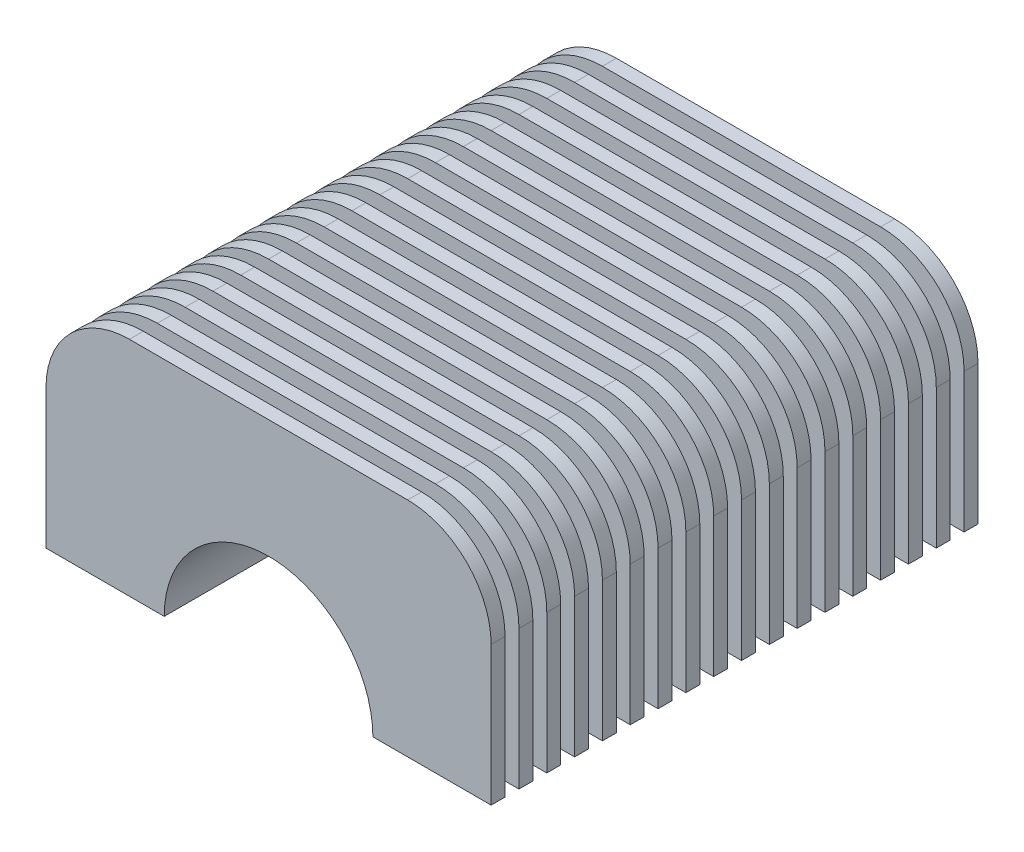
from build123d import *

# Parameters (mm, degrees)
BOSS_EXTRUDE1_DEPTH = 108
FILLET1_R           = 10
FILLET2_R           = 10
BOSS_EXTRUDE3_DEPTH = 3
LPATTERN1_COUNT     = 18
LPATTERN1_PITCH     = 6


with BuildPart() as part:
    # Sketch1 → Boss-Extrude1 (new body)
    with BuildSketch(Plane.XY):
        with BuildLine():
            Line((22.5, 0), (40, 0))
            Line((40, 0), (40, 40))
            Line((40, 40), (-40, 40))
            Line((-40, 40), (-40, 0))
            Line((-40, 0), (-22.5, 0))
            ThreePointArc((-22.5, 0), (0, 22.5), (22.5, 0))
        make_face()
    extrude(amount=BOSS_EXTRUDE1_DEPTH)

    # Fillet1
    fillet1_edges = [part.edges().sort_by_distance(p)[0] for p in [
        (-40, 40, 54),
    ]]
    fillet(fillet1_edges, radius=FILLET1_R)

    # Fillet2
    fillet2_edges = [part.edges().sort_by_distance(p)[0] for p in [
        (40, 40, 54),
    ]]
    fillet(fillet2_edges, radius=FILLET2_R)

    # Sketch3 → Boss-Extrude3 (add)
    with BuildSketch(Plane.XY.offset(108)):
        with BuildLine():
            Line((40, 0), (40, 30))
            ThreePointArc((40, 30), (37.071067812, 37.071067812), (30, 40))
            Line((30, 40), (-30, 40))
            ThreePointArc((-30, 40), (-37.071067812, 37.071067812), (-40, 30))
            Line((-40, 30), (-40, 0))
            Line((-40, 0), (-48, 0))
            Line((-48, 0), (-48, 30))
            ThreePointArc((-48, 30), (-42.727922061, 42.727922061), (-30, 48))
            Line((-30, 48), (30, 48))
            ThreePointArc((30, 48), (42.727922061, 42.727922061), (48, 30))
            Line((48, 30), (48, 0))
            Line((48, 0), (40, 0))
        make_face()
    boss_extrude3 = extrude(amount=-BOSS_EXTRUDE3_DEPTH)

    # LPattern1: Boss-Extrude3 ×18
    with Locations(*[(0, 0, -i * LPATTERN1_PITCH) for i in range(1, LPATTERN1_COUNT)]):
        add(boss_extrude3)


solid = part.part
